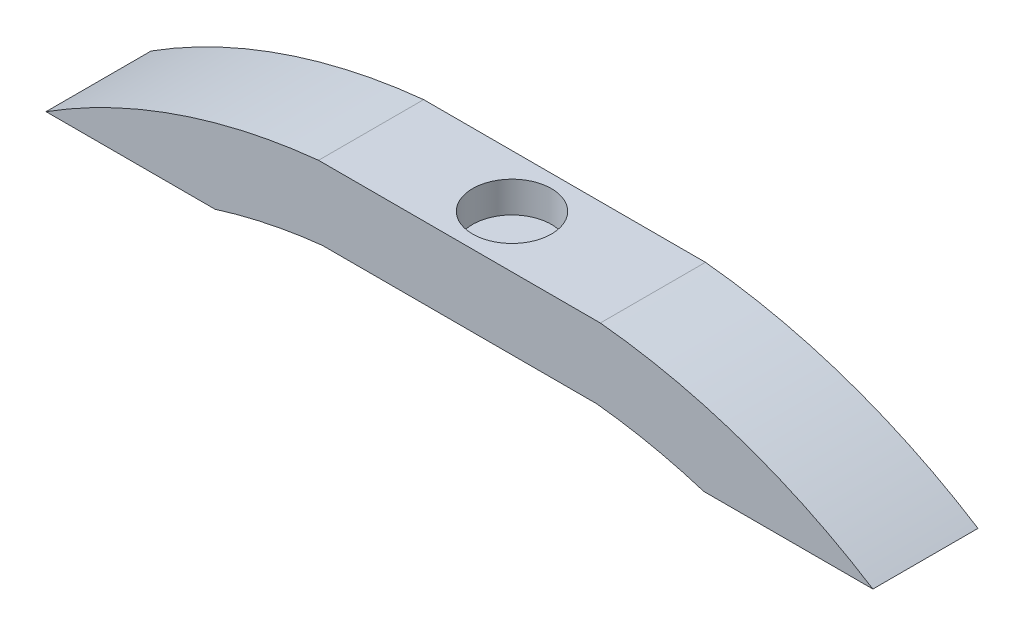
from build123d import *

# Parameters (mm, degrees)
BOSS_EXTRUDE1_DEPTH = 10.16
SKETCH2_R           = 3.81
CUT_EXTRUDE1_DEPTH  = 3


with BuildPart() as part:
    # Sketch1 → Boss-Extrude1 (new body)
    with BuildSketch(Plane.XY):
        with BuildLine():
            Line((-13.62, 60.264846167), (13.62, 60.264846167))
            ThreePointArc((13.62, 60.264846167), (27.323058228, 57.250841389), (39.965, 51.164846167))
            Line((39.965, 51.164846167), (23.620484036, 51.164846167))
            ThreePointArc((23.620484036, 51.164846167), (18.493954537, 52.501006754), (13.260607764, 53.324846167))
            Line((13.260607764, 53.324846167), (-13.260607764, 53.324846167))
            ThreePointArc((-13.260607764, 53.324846167), (-18.493954537, 52.501006754), (-23.620484036, 51.164846167))
            Line((-23.620484036, 51.164846167), (-39.965, 51.164846167))
            ThreePointArc((-39.965, 51.164846167), (-27.323058228, 57.250841389), (-13.62, 60.264846167))
        make_face()
    extrude(amount=BOSS_EXTRUDE1_DEPTH)

    # Sketch2 → Cut-Extrude1 (cut)
    with BuildSketch(Plane(origin=(0, 60.264846167, 0), x_dir=(1, 0, 0), z_dir=(0, 1, 0))):
        with Locations((0, -5.08)):
            Circle(SKETCH2_R)
    extrude(amount=-CUT_EXTRUDE1_DEPTH, mode=Mode.SUBTRACT)


solid = part.part
